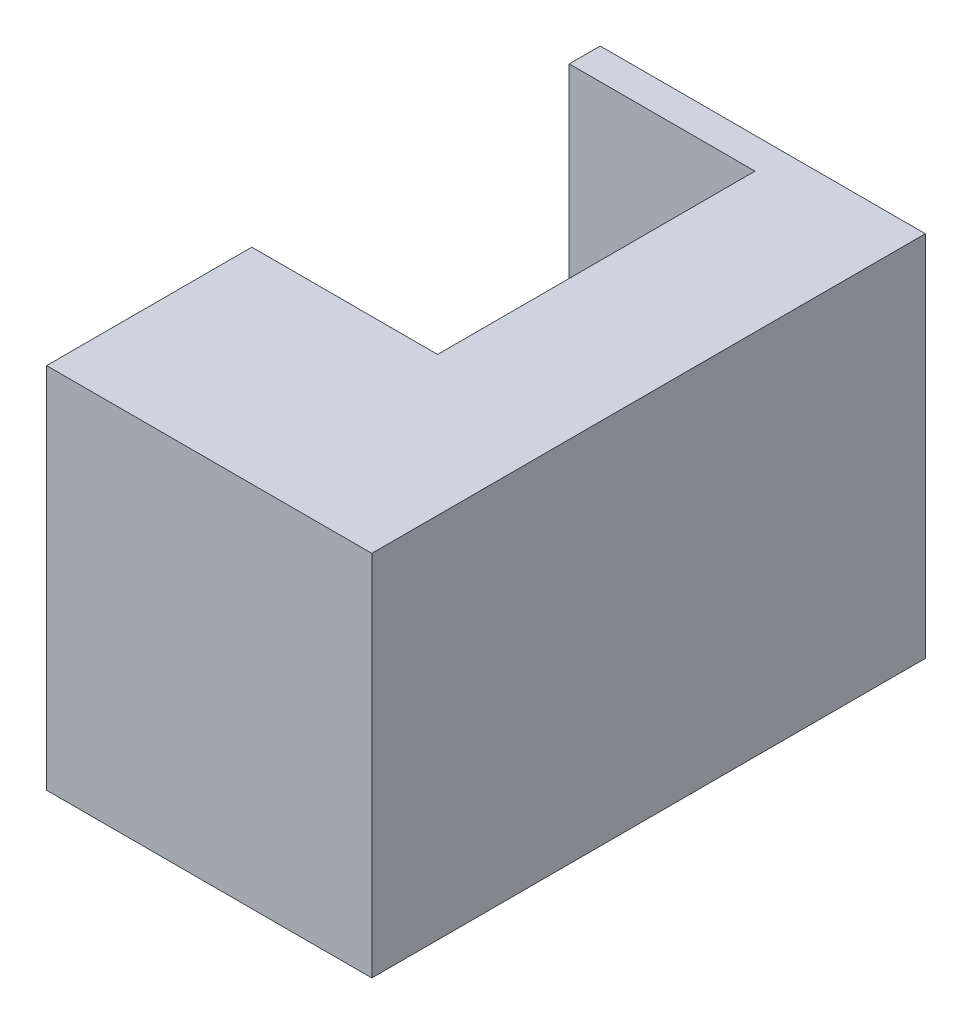
from build123d import *

# Parameters (mm, degrees)
SKETCH4_W           = 31.75
SKETCH4_H           = 19.75
BOSS_EXTRUDE1_DEPTH = 19
SHELL1_T            = 2
SKETCH5_W           = 12
SKETCH5_H           = 20.5
CUT_EXTRUDE1_DEPTH  = 2


with BuildPart() as part:
    # Sketch4 → Boss-Extrude1 (new body)
    with BuildSketch(Plane(origin=(0, 0, 0), x_dir=(0, 0, -1), z_dir=(1, 0, 0))):
        Rectangle(SKETCH4_W, SKETCH4_H)
    extrude(amount=BOSS_EXTRUDE1_DEPTH)

    # Shell1
    shell1_openings = [part.faces().sort_by_distance(p)[0] for p in [
        (0, 0, 0),
    ]]
    offset(amount=SHELL1_T, openings=shell1_openings, kind=Kind.INTERSECTION)

    # Sketch5 → Cut-Extrude1 (cut)
    with BuildSketch(Plane(origin=(0, 11.875, 0), x_dir=(1, 0, 0), z_dir=(0, 1, 0))):
        with Locations((6, 5.625)):
            Rectangle(SKETCH5_W, SKETCH5_H)
    extrude(amount=-CUT_EXTRUDE1_DEPTH, mode=Mode.SUBTRACT)


solid = part.part
